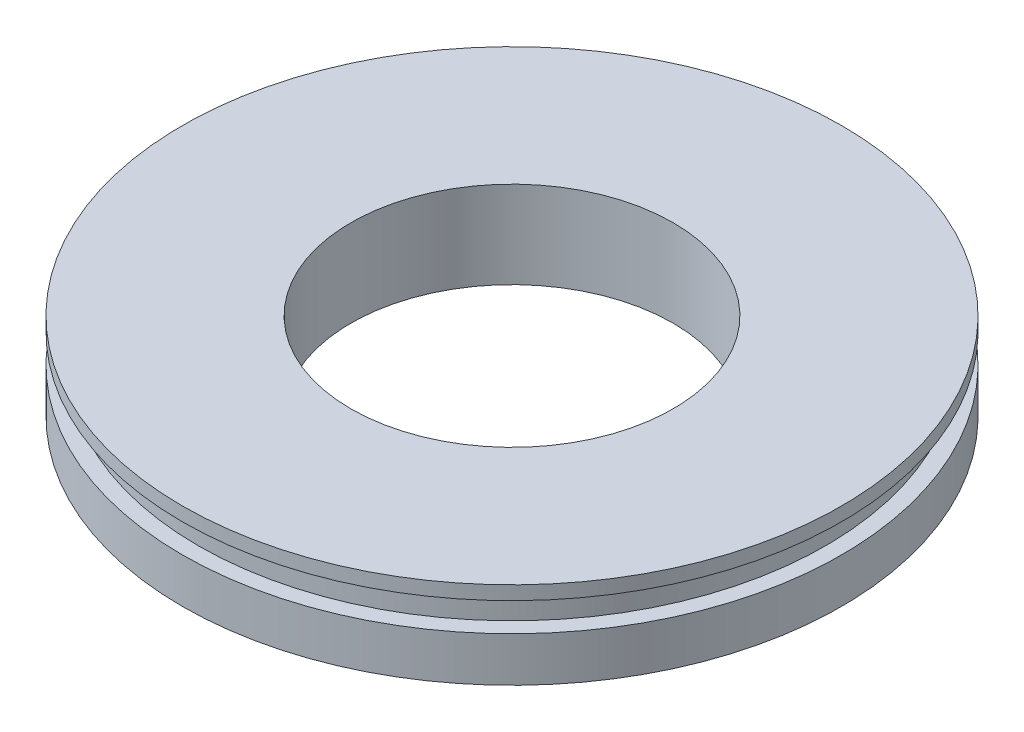
from build123d import *


with BuildPart() as part:
    # Sketch1 → Revolve1 (revolve)
    with BuildSketch(Plane(origin=(0, 0, 0), x_dir=(0, 0, -1), z_dir=(1, 0, 0))):
        Polygon((-14.2875, 2.694084), (-14.2875, -5.020818), (-29.21, -5.020818), (-29.21, -1.062068), (-27.80411, -1.062068), (-27.80411, 1.477932), (-29.21, 1.477932), (-29.21, 2.694084), align=None)
    revolve(axis=Axis((0, 0, 0), (0, -1, 0)))


solid = part.part
